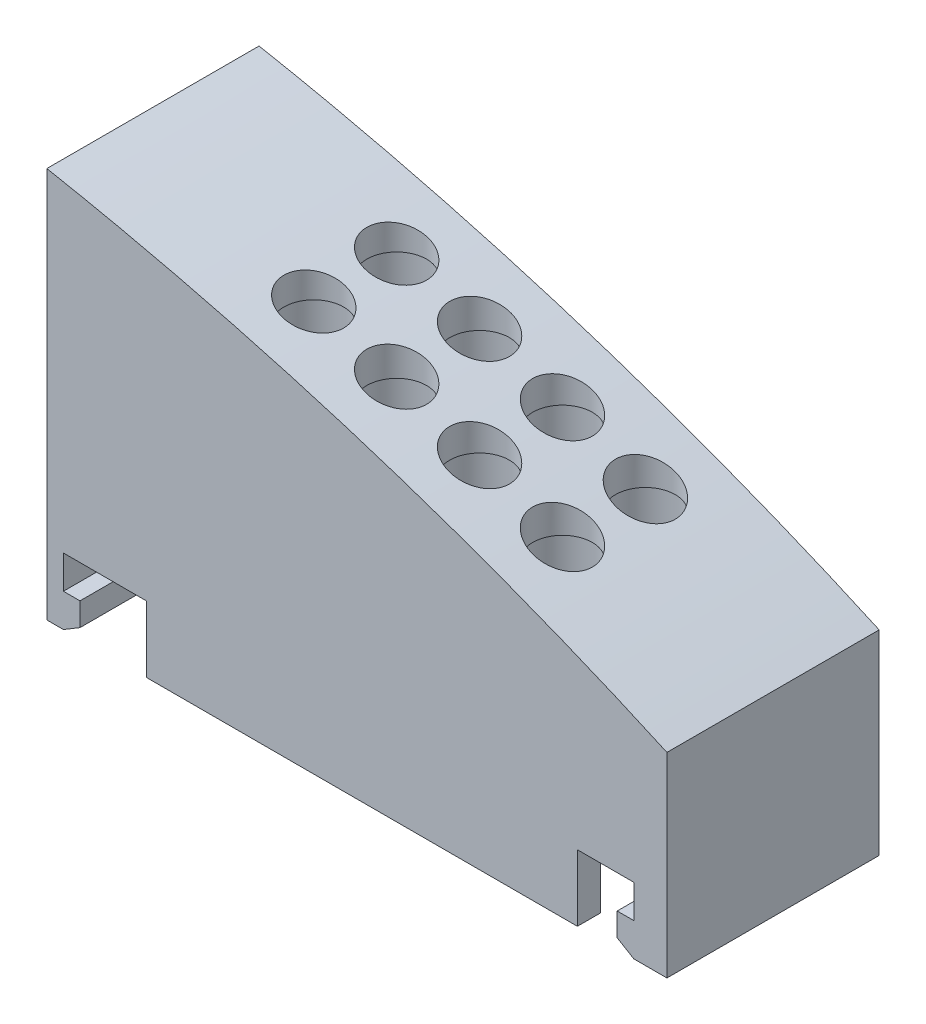
from build123d import *

# Parameters (mm, degrees)
SKETCH1_W             = 18.7
SKETCH1_H             = 6.4
BOSS_EXTRUDE1_DEPTH   = 13
SKETCH2_W             = 13
SKETCH2_H             = 0.7
SKETCH2_W_2           = 0.5
SKETCH2_H_2           = 6.4
SKETCH2_W_3           = 1
BOSS_EXTRUDE2_DEPTH   = 2
CUT_EXTRUDE1_REACH    = 17
SKETCH3_R             = 0.9
CUT_EXTRUDE2_REACH    = 8.4
SKETCH5_R             = 1.1
CUT_EXTRUDE3_DEPTH    = 5.4
SKETCH6_R             = 1.1
CUT_EXTRUDE4_DEPTH    = 6.3
SKETCH7_R             = 1.1
CUT_EXTRUDE5_DEPTH    = 7
SKETCH8_R             = 1.1
CUT_EXTRUDE6_DEPTH    = 7.8
SKETCH10_W            = 6.4
SKETCH10_H            = 1
BOSS_EXTRUDE3_DEPTH   = 0.5
SKETCH11_W            = 6.4
SKETCH11_H            = 1
BOSS_EXTRUDE4_DEPTH   = 0.5
CHAMFER1_SIZE         = 0.5
CHAMFER1_SIZE2        = 0.3
CHAMFER1_PART_2_SIZE  = 0.5
CHAMFER1_PART_2_SIZE2 = 0.3


with BuildPart() as part:
    # Sketch1 → Boss-Extrude1 (new body)
    with BuildSketch(Plane(origin=(0, 0, 0), x_dir=(1, 0, 0), z_dir=(0, 1, 0))):
        Rectangle(SKETCH1_W, SKETCH1_H)
    extrude(amount=BOSS_EXTRUDE1_DEPTH)

    # Sketch2 → Boss-Extrude2 (add)
    with BuildSketch(Plane.XZ):
        with Locations((0.15, 2.85)):
            Rectangle(SKETCH2_W, SKETCH2_H)
        with Locations((0.15, -2.85)):
            Rectangle(SKETCH2_W, SKETCH2_H)
        with Locations((-9.1, 0)):
            Rectangle(SKETCH2_W_2, SKETCH2_H_2)
        with Locations((8.85, 0)):
            Rectangle(SKETCH2_W_3, SKETCH2_H_2)
    extrude(amount=BOSS_EXTRUDE2_DEPTH)

    # Sketch3 → Cut-Extrude1 (cut, up to next)
    with BuildSketch(Plane(origin=(0, 13, 0), x_dir=(1, 0, 0), z_dir=(0, 1, 0)), mode=Mode.PRIVATE) as cut_extrude1_sk1:
        with Locations(Location((4.25, -1.25, 0), (0, 0, 270))):  # turned: the seam where the file's is
            Circle(SKETCH3_R)
    cut_extrude1_tool1 = extrude(cut_extrude1_sk1.sketch, amount=-CUT_EXTRUDE1_REACH, mode=Mode.PRIVATE) & part.part
    add(cut_extrude1_tool1.solids().sort_by_distance((4.25, 13, 1.25))[0], mode=Mode.SUBTRACT)
    # Sketch3 → Cut-Extrude1 (cut, up to next)
    with BuildSketch(Plane(origin=(0, 13, 0), x_dir=(1, 0, 0), z_dir=(0, 1, 0)), mode=Mode.PRIVATE) as cut_extrude1_sk2:
        with Locations(Location((1.75, -1.25, 0), (0, 0, 270))):  # turned: the seam where the file's is
            Circle(SKETCH3_R)
    cut_extrude1_tool2 = extrude(cut_extrude1_sk2.sketch, amount=-CUT_EXTRUDE1_REACH, mode=Mode.PRIVATE) & part.part
    add(cut_extrude1_tool2.solids().sort_by_distance((1.75, 13, 1.25))[0], mode=Mode.SUBTRACT)
    # Sketch3 → Cut-Extrude1 (cut, up to next)
    with BuildSketch(Plane(origin=(0, 13, 0), x_dir=(1, 0, 0), z_dir=(0, 1, 0)), mode=Mode.PRIVATE) as cut_extrude1_sk3:
        with Locations(Location((-0.75, -1.25, 0), (0, 0, 270))):  # turned: the seam where the file's is
            Circle(SKETCH3_R)
    cut_extrude1_tool3 = extrude(cut_extrude1_sk3.sketch, amount=-CUT_EXTRUDE1_REACH, mode=Mode.PRIVATE) & part.part
    add(cut_extrude1_tool3.solids().sort_by_distance((-0.75, 13, 1.25))[0], mode=Mode.SUBTRACT)
    # Sketch3 → Cut-Extrude1 (cut, up to next)
    with BuildSketch(Plane(origin=(0, 13, 0), x_dir=(1, 0, 0), z_dir=(0, 1, 0)), mode=Mode.PRIVATE) as cut_extrude1_sk4:
        with Locations(Location((-3.25, -1.25, 0), (0, 0, 270))):  # turned: the seam where the file's is
            Circle(SKETCH3_R)
    cut_extrude1_tool4 = extrude(cut_extrude1_sk4.sketch, amount=-CUT_EXTRUDE1_REACH, mode=Mode.PRIVATE) & part.part
    add(cut_extrude1_tool4.solids().sort_by_distance((-3.25, 13, 1.25))[0], mode=Mode.SUBTRACT)
    # Sketch3 → Cut-Extrude1 (cut, up to next)
    with BuildSketch(Plane(origin=(0, 13, 0), x_dir=(1, 0, 0), z_dir=(0, 1, 0)), mode=Mode.PRIVATE) as cut_extrude1_sk5:
        with Locations(Location((4.25, 1.25, 0), (0, 0, 270))):  # turned: the seam where the file's is
            Circle(SKETCH3_R)
    cut_extrude1_tool5 = extrude(cut_extrude1_sk5.sketch, amount=-CUT_EXTRUDE1_REACH, mode=Mode.PRIVATE) & part.part
    add(cut_extrude1_tool5.solids().sort_by_distance((4.25, 13, -1.25))[0], mode=Mode.SUBTRACT)
    # Sketch3 → Cut-Extrude1 (cut, up to next)
    with BuildSketch(Plane(origin=(0, 13, 0), x_dir=(1, 0, 0), z_dir=(0, 1, 0)), mode=Mode.PRIVATE) as cut_extrude1_sk6:
        with Locations(Location((1.75, 1.25, 0), (0, 0, 270))):  # turned: the seam where the file's is
            Circle(SKETCH3_R)
    cut_extrude1_tool6 = extrude(cut_extrude1_sk6.sketch, amount=-CUT_EXTRUDE1_REACH, mode=Mode.PRIVATE) & part.part
    add(cut_extrude1_tool6.solids().sort_by_distance((1.75, 13, -1.25))[0], mode=Mode.SUBTRACT)
    # Sketch3 → Cut-Extrude1 (cut, up to next)
    with BuildSketch(Plane(origin=(0, 13, 0), x_dir=(1, 0, 0), z_dir=(0, 1, 0)), mode=Mode.PRIVATE) as cut_extrude1_sk7:
        with Locations(Location((-0.75, 1.25, 0), (0, 0, 270))):  # turned: the seam where the file's is
            Circle(SKETCH3_R)
    cut_extrude1_tool7 = extrude(cut_extrude1_sk7.sketch, amount=-CUT_EXTRUDE1_REACH, mode=Mode.PRIVATE) & part.part
    add(cut_extrude1_tool7.solids().sort_by_distance((-0.75, 13, -1.25))[0], mode=Mode.SUBTRACT)
    # Sketch3 → Cut-Extrude1 (cut, up to next)
    with BuildSketch(Plane(origin=(0, 13, 0), x_dir=(1, 0, 0), z_dir=(0, 1, 0)), mode=Mode.PRIVATE) as cut_extrude1_sk8:
        with Locations(Location((-3.25, 1.25, 0), (0, 0, 270))):  # turned: the seam where the file's is
            Circle(SKETCH3_R)
    cut_extrude1_tool8 = extrude(cut_extrude1_sk8.sketch, amount=-CUT_EXTRUDE1_REACH, mode=Mode.PRIVATE) & part.part
    add(cut_extrude1_tool8.solids().sort_by_distance((-3.25, 13, -1.25))[0], mode=Mode.SUBTRACT)

    # Sketch4 → Cut-Extrude2 (cut, up to next)
    with BuildSketch(Plane(origin=(0, 0, -3.2), x_dir=(-1, 0, 0), z_dir=(0, 0, -1)), mode=Mode.PRIVATE) as cut_extrude2_sk1:
        with BuildLine():
            Line((-9.35, 13), (9.35, 13))
            Line((9.35, 13), (9.35, 9.790050428))
            add(Edge.make_bspline(
                [(9.35, 9.790050428), (-0.455442008, 7.925691322), (-9.35, 3.892093752)],
                knots=[1.786761572, 1.786761572, 1.786761572, 2.052876958, 2.052876958, 2.052876958], degree=2, weights=[1, 0.991160878, 1]))
            Line((-9.35, 3.892093752), (-9.35, 13))
        make_face()
    cut_extrude2_tool1 = extrude(cut_extrude2_sk1.sketch, amount=-CUT_EXTRUDE2_REACH, mode=Mode.PRIVATE) & part.part
    add(cut_extrude2_tool1.solids().sort_by_distance((1.591729, 9.871634, -3.2))[0], mode=Mode.SUBTRACT)

    # Sketch5 → Cut-Extrude3 (cut)
    with BuildSketch(Plane.XZ):
        with Locations(Location((4.25, -1.25, 0), (0, 0, 270))):  # turned: the seam where the file's is
            Circle(SKETCH5_R)
        with Locations(Location((4.25, 1.25, 0), (0, 0, 270))):  # turned: the seam where the file's is
            Circle(SKETCH5_R)
    extrude(amount=-CUT_EXTRUDE3_DEPTH, mode=Mode.SUBTRACT)

    # Sketch6 → Cut-Extrude4 (cut)
    with BuildSketch(Plane.XZ):
        with Locations(Location((1.75, 1.25, 0), (0, 0, 270))):  # turned: the seam where the file's is
            Circle(SKETCH6_R)
        with Locations(Location((1.75, -1.25, 0), (0, 0, 270))):  # turned: the seam where the file's is
            Circle(SKETCH6_R)
    extrude(amount=-CUT_EXTRUDE4_DEPTH, mode=Mode.SUBTRACT)

    # Sketch7 → Cut-Extrude5 (cut)
    with BuildSketch(Plane.XZ):
        with Locations(Location((-0.75, 1.25, 0), (0, 0, 270))):  # turned: the seam where the file's is
            Circle(SKETCH7_R)
        with Locations(Location((-0.75, -1.25, 0), (0, 0, 270))):  # turned: the seam where the file's is
            Circle(SKETCH7_R)
    extrude(amount=-CUT_EXTRUDE5_DEPTH, mode=Mode.SUBTRACT)

    # Sketch8 → Cut-Extrude6 (cut)
    with BuildSketch(Plane.XZ):
        with Locations(Location((-3.25, 1.25, 0), (0, 0, 270))):  # turned: the seam where the file's is
            Circle(SKETCH8_R)
        with Locations(Location((-3.25, -1.25, 0), (0, 0, 270))):  # turned: the seam where the file's is
            Circle(SKETCH8_R)
    extrude(amount=-CUT_EXTRUDE6_DEPTH, mode=Mode.SUBTRACT)

    # Sketch10 → Boss-Extrude3 (add)
    with BuildSketch(Plane.ZY.offset(-8.35)):
        with Locations((0, -1.5)):
            Rectangle(SKETCH10_W, SKETCH10_H)
    extrude(amount=BOSS_EXTRUDE3_DEPTH)

    # Sketch11 → Boss-Extrude4 (add)
    with BuildSketch(Plane(origin=(-8.85, 0, 0), x_dir=(0, 0, -1), z_dir=(1, 0, 0))):
        with Locations((0, -1.5)):
            Rectangle(SKETCH11_W, SKETCH11_H)
    extrude(amount=BOSS_EXTRUDE4_DEPTH)

    # Chamfer1
    chamfer1_edges = [part.edges().sort_by_distance(p)[0] for p in [
        (7.85, -2, 0),
    ]]
    chamfer1_side = [part.faces().sort_by_distance(p)[0] for p in [
        (8.6, -2, 0),
    ]]
    chamfer(chamfer1_edges, length=CHAMFER1_SIZE, length2=CHAMFER1_SIZE2, reference=chamfer1_side[0])

    # Chamfer1 part 2
    chamfer1_part_2_edges = [part.edges().sort_by_distance(p)[0] for p in [
        (-8.35, -2, 0),
    ]]
    chamfer1_part_2_side = [part.faces().sort_by_distance(p)[0] for p in [
        (-8.85, -2, 0),
    ]]
    chamfer(chamfer1_part_2_edges, length=CHAMFER1_PART_2_SIZE, length2=CHAMFER1_PART_2_SIZE2, reference=chamfer1_part_2_side[0])


solid = part.part
